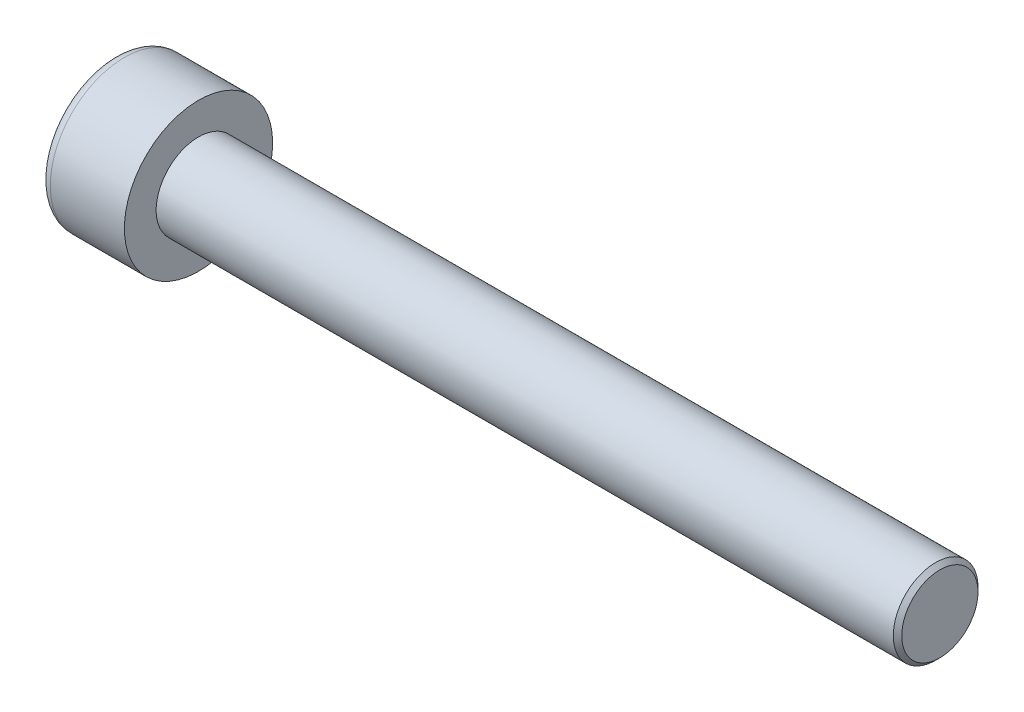
from build123d import *

# Parameters (mm, degrees)
SKETCH1_R           = 3.5
BASEHEAD_DEPTH      = 4
SKETCH2_R           = 2
BASEBODY_DEPTH      = 35
HEXAGONSOCKET_DEPTH = 2
TOPFILLET_R         = 0.5
CHAMFER1_SIZE       = 0.2


with BuildPart() as part:
    # Sketch1 → BaseHead (new body)
    with BuildSketch(Plane(origin=(0, 0, 0), x_dir=(0, 0, -1), z_dir=(1, 0, 0))):
        Circle(SKETCH1_R)
    extrude(amount=BASEHEAD_DEPTH)

    # Sketch2 → BaseBody (add)
    with BuildSketch(Plane(origin=(4, 0, 0), x_dir=(0, 0, -1), z_dir=(1, 0, 0))):
        Circle(SKETCH2_R)
    extrude(amount=BASEBODY_DEPTH)

    # Sketch3 → HexagonSocket (cut)
    with BuildSketch(Plane(origin=(0, 0, 0), x_dir=(0, 0, -1), z_dir=(1, 0, 0))):
        Polygon((1.732050808, 0), (0.866025404, 1.5), (-0.866025404, 1.5), (-1.732050808, 0), (-0.866025404, -1.5), (0.866025404, -1.5), align=None)
    extrude(amount=HEXAGONSOCKET_DEPTH, mode=Mode.SUBTRACT)

    # Sketch4 → Cut-Revolve1 (revolve, cut)
    with BuildSketch(Plane(origin=(-4.19613823, 0.75, 0), x_dir=(-1, 0, 0), z_dir=(0, 0, 1))):
        Polygon((-6.19613823, 2.25), (-7.062163633, 0.75), (-6.19613823, 0.75), align=None)
    revolve(axis=Axis((0.838992387, 0, 0), (-1, 0, 0)), mode=Mode.SUBTRACT)

    # TopFillet
    topfillet_edges = [part.edges().sort_by_distance(p)[0] for p in [
        (0, 0, 3.5),
    ]]
    fillet(topfillet_edges, radius=TOPFILLET_R)

    # Chamfer1
    chamfer1_edges = [part.edges().sort_by_distance(p)[0] for p in [
        (39, 0, 2),
    ]]
    chamfer(chamfer1_edges, length=CHAMFER1_SIZE)


solid = part.part
